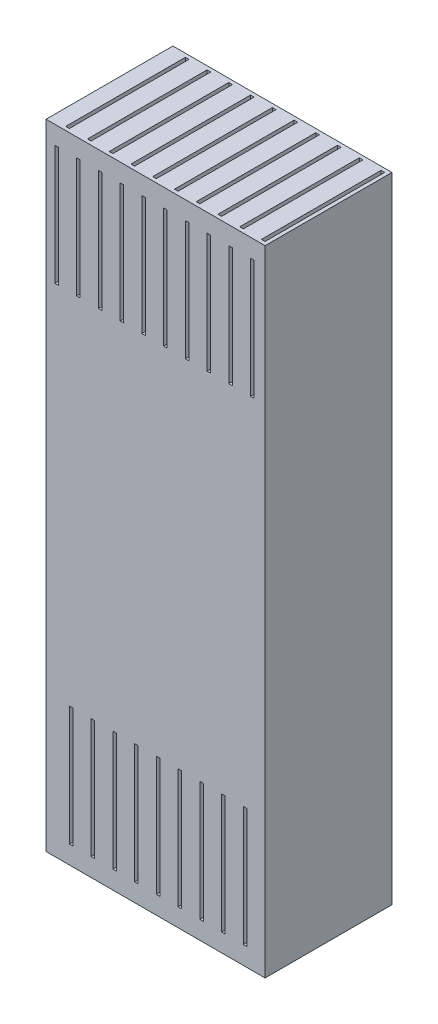
from build123d import *

# Parameters (mm, degrees)
SKETCH1_W           = 120.851681216
SKETCH1_H           = 70
BOSS_EXTRUDE1_DEPTH = 350
SKETCH2_W           = 2
SKETCH2_H           = 66
CUT_EXTRUDE1_DEPTH  = 350
LPATTERN1_COUNT     = 10
LPATTERN1_PITCH     = 12
SKETCH3_W           = 2
SKETCH3_H           = 66
CUT_EXTRUDE2_DEPTH  = 340
LPATTERN2_COUNT     = 10
LPATTERN2_PITCH     = 12
SKETCH4_W           = 2
SKETCH4_H           = 66
CUT_EXTRUDE3_DEPTH  = 340
LPATTERN3_COUNT     = 10
LPATTERN3_PITCH     = 12
SKETCH5_W           = 2
SKETCH5_H           = 66
CUT_EXTRUDE4_DEPTH  = 68
LPATTERN4_COUNT     = 9
LPATTERN4_PITCH     = 12
SKETCH6_W           = 2
SKETCH6_H           = 66
CUT_EXTRUDE5_DEPTH  = 68
LPATTERN5_COUNT     = 9
LPATTERN5_PITCH     = 12
SKETCH7_W           = 2
SKETCH7_H           = 66
CUT_EXTRUDE6_DEPTH  = 68
LPATTERN6_COUNT     = 10
LPATTERN6_PITCH     = 12
SKETCH8_W           = 2
SKETCH8_H           = 66
CUT_EXTRUDE7_DEPTH  = 68
LPATTERN7_COUNT     = 10
LPATTERN7_PITCH     = 12
SKETCH9_W           = 2
SKETCH9_H           = 66
BOSS_EXTRUDE2_DEPTH = 10
LPATTERN9_COUNT     = 10
LPATTERN9_PITCH     = 12
SKETCH11_W          = 2
SKETCH11_H          = 66
BOSS_EXTRUDE4_DEPTH = 10
LPATTERN10_COUNT    = 9
LPATTERN10_PITCH    = 12


with BuildPart() as part:
    # Sketch1 → Boss-Extrude1 (new body)
    with BuildSketch(Plane(origin=(0, 0, 0), x_dir=(1, 0, 0), z_dir=(0, 1, 0))):
        Rectangle(SKETCH1_W, SKETCH1_H)
    extrude(amount=BOSS_EXTRUDE1_DEPTH)

    # Sketch2 → Cut-Extrude1 (cut)
    with BuildSketch(Plane(origin=(0, 350, 0), x_dir=(1, 0, 0), z_dir=(0, 1, 0))):
        with Locations((57.425840608, 0)):
            Rectangle(SKETCH2_W, SKETCH2_H)
    cut_extrude1 = extrude(amount=-CUT_EXTRUDE1_DEPTH, mode=Mode.SUBTRACT)

    # LPattern1: Cut-Extrude1 ×10
    with Locations(*[(-i * LPATTERN1_PITCH, 0, 0) for i in range(1, LPATTERN1_COUNT)]):
        add(cut_extrude1, mode=Mode.SUBTRACT)

    # Sketch3 → Cut-Extrude2 (cut)
    with BuildSketch(Plane(origin=(0, 350, 0), x_dir=(1, 0, 0), z_dir=(0, 1, 0))):
        with Locations((53.425840608, 0)):
            Rectangle(SKETCH3_W, SKETCH3_H)
    cut_extrude2 = extrude(amount=-CUT_EXTRUDE2_DEPTH, mode=Mode.SUBTRACT)

    # LPattern2: Cut-Extrude2 ×10
    with Locations(*[(-i * LPATTERN2_PITCH, 0, 0) for i in range(1, LPATTERN2_COUNT)]):
        add(cut_extrude2, mode=Mode.SUBTRACT)

    # Sketch4 → Cut-Extrude3 (cut)
    with BuildSketch(Plane.XZ):
        with Locations((-46.574159392, 0)):
            Rectangle(SKETCH4_W, SKETCH4_H)
    cut_extrude3 = extrude(amount=-CUT_EXTRUDE3_DEPTH, mode=Mode.SUBTRACT)

    # LPattern3: Cut-Extrude3 ×10
    with Locations(*[(i * LPATTERN3_PITCH, 0, 0) for i in range(1, LPATTERN3_COUNT)]):
        add(cut_extrude3, mode=Mode.SUBTRACT)

    # Sketch5 → Cut-Extrude4 (cut)
    with BuildSketch(Plane(origin=(0, 0, -35), x_dir=(-1, 0, 0), z_dir=(0, 0, -1))):
        with Locations((-49.425840608, 307)):
            Rectangle(SKETCH5_W, SKETCH5_H)
    cut_extrude4 = extrude(amount=-CUT_EXTRUDE4_DEPTH, mode=Mode.SUBTRACT)

    # LPattern4: Cut-Extrude4 ×9
    with Locations(*[(-i * LPATTERN4_PITCH, 0, 0) for i in range(1, LPATTERN4_COUNT)]):
        add(cut_extrude4, mode=Mode.SUBTRACT)

    # Sketch6 → Cut-Extrude5 (cut)
    with BuildSketch(Plane.XY.offset(35)):
        with Locations((49.425840608, 43)):
            Rectangle(SKETCH6_W, SKETCH6_H)
    cut_extrude5 = extrude(amount=-CUT_EXTRUDE5_DEPTH, mode=Mode.SUBTRACT)

    # LPattern5: Cut-Extrude5 ×9
    with Locations(*[(-i * LPATTERN5_PITCH, 0, 0) for i in range(1, LPATTERN5_COUNT)]):
        add(cut_extrude5, mode=Mode.SUBTRACT)

    # Sketch7 → Cut-Extrude6 (cut)
    with BuildSketch(Plane(origin=(0, 0, -35), x_dir=(-1, 0, 0), z_dir=(0, 0, -1))):
        with Locations((-53.425840608, 43)):
            Rectangle(SKETCH7_W, SKETCH7_H)
    cut_extrude6 = extrude(amount=-CUT_EXTRUDE6_DEPTH, mode=Mode.SUBTRACT)

    # LPattern6: Cut-Extrude6 ×10
    with Locations(*[(-i * LPATTERN6_PITCH, 0, 0) for i in range(1, LPATTERN6_COUNT)]):
        add(cut_extrude6, mode=Mode.SUBTRACT)

    # Sketch8 → Cut-Extrude7 (cut)
    with BuildSketch(Plane.XY.offset(35)):
        with Locations((53.425840608, 307)):
            Rectangle(SKETCH8_W, SKETCH8_H)
    cut_extrude7 = extrude(amount=-CUT_EXTRUDE7_DEPTH, mode=Mode.SUBTRACT)

    # LPattern7: Cut-Extrude7 ×10
    with Locations(*[(-i * LPATTERN7_PITCH, 0, 0) for i in range(1, LPATTERN7_COUNT)]):
        add(cut_extrude7, mode=Mode.SUBTRACT)


with BuildPart() as body_2:
    # Sketch9 → Boss-Extrude2 (new body)
    with BuildSketch(Plane(origin=(0, 350, 0), x_dir=(1, 0, 0), z_dir=(0, 1, 0))):
        with Locations((53.425840608, 0)):
            Rectangle(SKETCH9_W, SKETCH9_H)
    boss_extrude2 = extrude(amount=-BOSS_EXTRUDE2_DEPTH)


with BuildPart() as lpattern9_1:
    # LPattern9: pattern copy
    add(boss_extrude2.moved(Location(Vector(-1, 0, 0) * (1 * LPATTERN9_PITCH))))


with BuildPart() as lpattern9_2:
    # LPattern9: pattern copy
    add(boss_extrude2.moved(Location(Vector(-1, 0, 0) * (2 * LPATTERN9_PITCH))))


with BuildPart() as lpattern9_3:
    # LPattern9: pattern copy
    add(boss_extrude2.moved(Location(Vector(-1, 0, 0) * (3 * LPATTERN9_PITCH))))


with BuildPart() as lpattern9_4:
    # LPattern9: pattern copy
    add(boss_extrude2.moved(Location(Vector(-1, 0, 0) * (4 * LPATTERN9_PITCH))))


with BuildPart() as lpattern9_5:
    # LPattern9: pattern copy
    add(boss_extrude2.moved(Location(Vector(-1, 0, 0) * (5 * LPATTERN9_PITCH))))


with BuildPart() as lpattern9_6:
    # LPattern9: pattern copy
    add(boss_extrude2.moved(Location(Vector(-1, 0, 0) * (6 * LPATTERN9_PITCH))))


with BuildPart() as lpattern9_7:
    # LPattern9: pattern copy
    add(boss_extrude2.moved(Location(Vector(-1, 0, 0) * (7 * LPATTERN9_PITCH))))


with BuildPart() as lpattern9_8:
    # LPattern9: pattern copy
    add(boss_extrude2.moved(Location(Vector(-1, 0, 0) * (8 * LPATTERN9_PITCH))))


with BuildPart() as lpattern9_9:
    # LPattern9: pattern copy
    add(boss_extrude2.moved(Location(Vector(-1, 0, 0) * (9 * LPATTERN9_PITCH))))


with BuildPart() as part_1:
    add(part.part)

    # Combine2: union LPattern9_1, LPattern9_2, LPattern9_3, LPattern9_4, LPattern9_5, LPattern9_6, LPattern9_7, LPattern9_8, LPattern9_9, body 2
    add(lpattern9_1.part)
    add(lpattern9_2.part)
    add(lpattern9_3.part)
    add(lpattern9_4.part)
    add(lpattern9_5.part)
    add(lpattern9_6.part)
    add(lpattern9_7.part)
    add(lpattern9_8.part)
    add(lpattern9_9.part)
    add(body_2.part)

    # Sketch11 → Boss-Extrude4 (add)
    with BuildSketch(Plane.XZ):
        with Locations((49.425840608, 0)):
            Rectangle(SKETCH11_W, SKETCH11_H)
    boss_extrude4 = extrude(amount=-BOSS_EXTRUDE4_DEPTH)

    # LPattern10: Boss-Extrude4 ×9
    with Locations(*[(-i * LPATTERN10_PITCH, 0, 0) for i in range(1, LPATTERN10_COUNT)]):
        add(boss_extrude4)


solid = part_1.part
